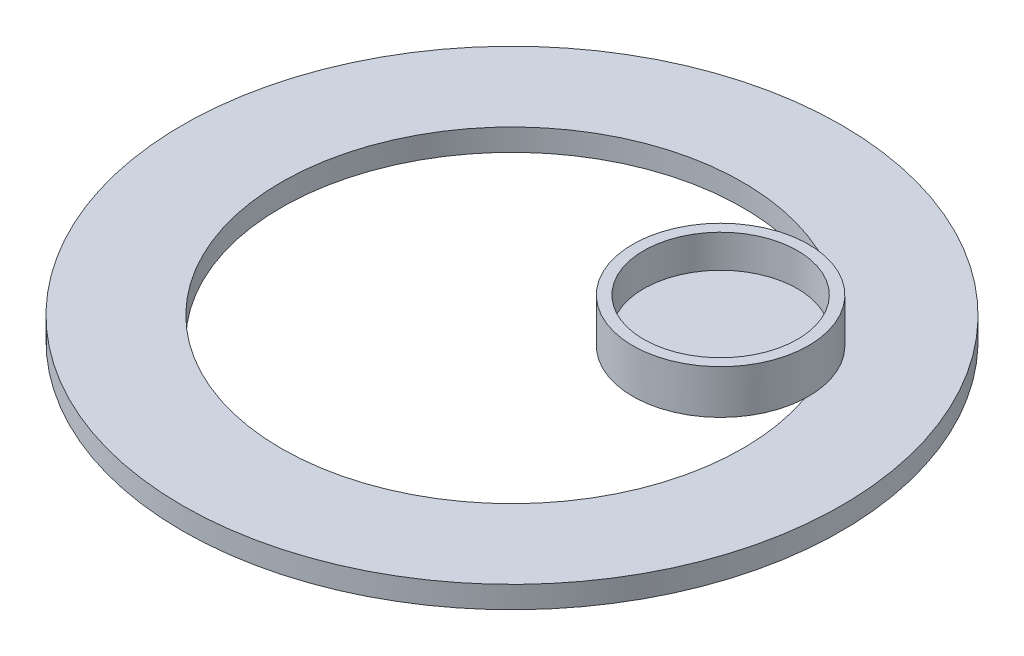
from build123d import *

# Parameters (mm, degrees)
SKETCH1_R           = 30
BOSS_EXTRUDE1_DEPTH = 2
SKETCH2_R           = 21
CUT_EXTRUDE1_DEPTH  = 2
SKETCH3_R           = 8
BOSS_EXTRUDE2_DEPTH = 4
SKETCH4_R           = 7
CUT_EXTRUDE2_DEPTH  = 3


with BuildPart() as part:
    # Sketch1 → Boss-Extrude1 (new body)
    with BuildSketch(Plane(origin=(0, 0, 0), x_dir=(1, 0, 0), z_dir=(0, 1, 0))):
        Circle(SKETCH1_R)
    extrude(amount=BOSS_EXTRUDE1_DEPTH)

    # Sketch2 → Cut-Extrude1 (cut)
    with BuildSketch(Plane(origin=(0, 2, 0), x_dir=(1, 0, 0), z_dir=(0, 1, 0))):
        Circle(SKETCH2_R)
    extrude(amount=-CUT_EXTRUDE1_DEPTH, mode=Mode.SUBTRACT)

    # Sketch3 → Boss-Extrude2 (add)
    with BuildSketch(Plane(origin=(0, 2, 0), x_dir=(1, 0, 0), z_dir=(0, 1, 0))):
        with Locations((11.890730665, 7.098367026)):
            Circle(SKETCH3_R)
    extrude(amount=BOSS_EXTRUDE2_DEPTH)

    # Sketch4 → Cut-Extrude2 (cut)
    with BuildSketch(Plane(origin=(0, 6, 0), x_dir=(1, 0, 0), z_dir=(0, 1, 0))):
        with Locations((11.890730665, 7.098367026)):
            Circle(SKETCH4_R)
    extrude(amount=-CUT_EXTRUDE2_DEPTH, mode=Mode.SUBTRACT)


solid = part.part
